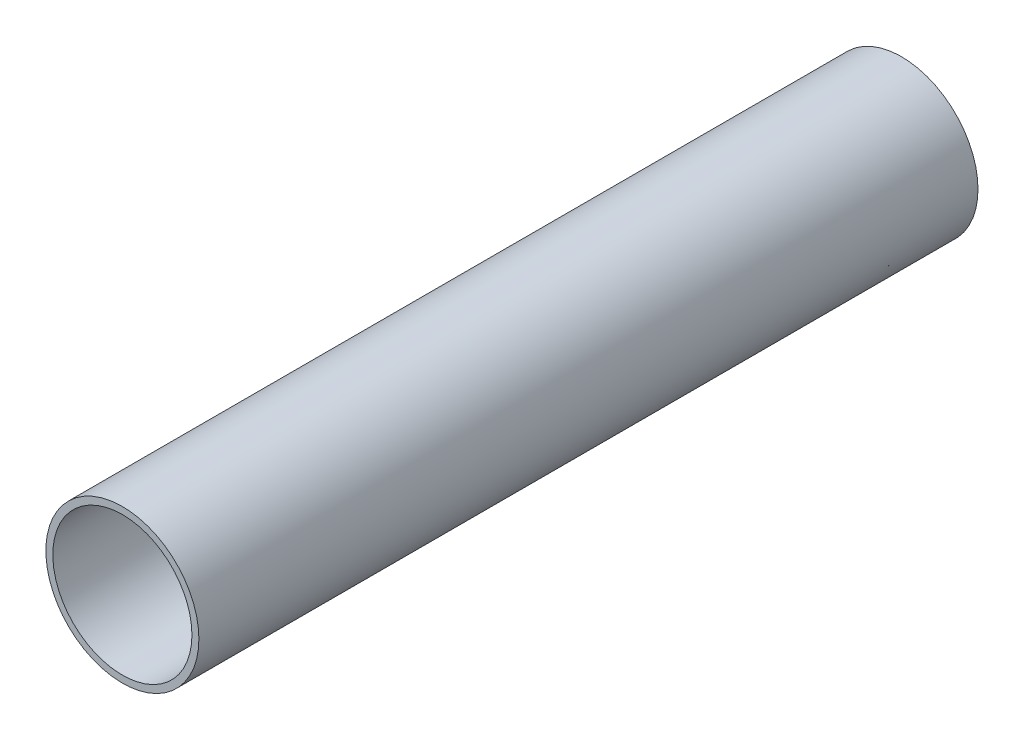
from build123d import *

# Parameters (mm, degrees)
ESQUISSE1_R                    = 5.5
ESQUISSE1_R_2                  = 5
BOSS_EXTRU_1_DEPTH             = 28
BOSS_EXTRU_2_REACH             = 7.5
ESQUISSE2_R                    = 1
BOSS_EXTRU_2_DIRECTION_2_REACH = 7.5


with BuildPart() as part:
    # Esquisse1 → Boss.-Extru.1 (new body, symmetric)
    with BuildSketch(Plane.XY):
        Circle(ESQUISSE1_R)
        Circle(ESQUISSE1_R_2, mode=Mode.SUBTRACT)
    extrude(amount=BOSS_EXTRU_1_DEPTH, both=True)

    # Esquisse2 → Boss.-Extru.2 (add, up to next)
    with BuildSketch(Plane(origin=(0, 0, 0), x_dir=(1, 0, 0), z_dir=(0, 1, 0)), mode=Mode.PRIVATE) as boss_extru_2_sk1:
        with Locations((0, -19.5)):
            Circle(ESQUISSE2_R)
    boss_extru_2_tool1 = extrude(boss_extru_2_sk1.sketch, amount=BOSS_EXTRU_2_REACH, mode=Mode.PRIVATE) - part.part
    add(boss_extru_2_tool1.solids().sort_by_distance((0, 0, 19.5))[0])
    # Esquisse2 → Boss.-Extru.2 (add, up to next)
    with BuildSketch(Plane(origin=(0, 0, 0), x_dir=(1, 0, 0), z_dir=(0, 1, 0)), mode=Mode.PRIVATE) as boss_extru_2_sk2:
        with Locations((0, 27)):
            Circle(ESQUISSE2_R)
    boss_extru_2_tool2 = extrude(boss_extru_2_sk2.sketch, amount=BOSS_EXTRU_2_REACH, mode=Mode.PRIVATE) - part.part
    add(boss_extru_2_tool2.solids().sort_by_distance((0, 0, -27))[0])

    # Esquisse2 → Boss.-Extru.2 direction 2 (add, up to next)
    with BuildSketch(Plane(origin=(0, 0, 0), x_dir=(1, 0, 0), z_dir=(0, 1, 0)), mode=Mode.PRIVATE) as boss_extru_2_direction_2_sk1:
        with Locations((0, -19.5)):
            Circle(ESQUISSE2_R)
    boss_extru_2_direction_2_tool1 = extrude(boss_extru_2_direction_2_sk1.sketch, amount=-BOSS_EXTRU_2_DIRECTION_2_REACH, mode=Mode.PRIVATE) - part.part
    add(boss_extru_2_direction_2_tool1.solids().sort_by_distance((0, 0, 19.5))[0])
    # Esquisse2 → Boss.-Extru.2 direction 2 (add, up to next)
    with BuildSketch(Plane(origin=(0, 0, 0), x_dir=(1, 0, 0), z_dir=(0, 1, 0)), mode=Mode.PRIVATE) as boss_extru_2_direction_2_sk2:
        with Locations((0, 27)):
            Circle(ESQUISSE2_R)
    boss_extru_2_direction_2_tool2 = extrude(boss_extru_2_direction_2_sk2.sketch, amount=-BOSS_EXTRU_2_DIRECTION_2_REACH, mode=Mode.PRIVATE) - part.part
    add(boss_extru_2_direction_2_tool2.solids().sort_by_distance((0, 0, -27))[0])


solid = part.part
